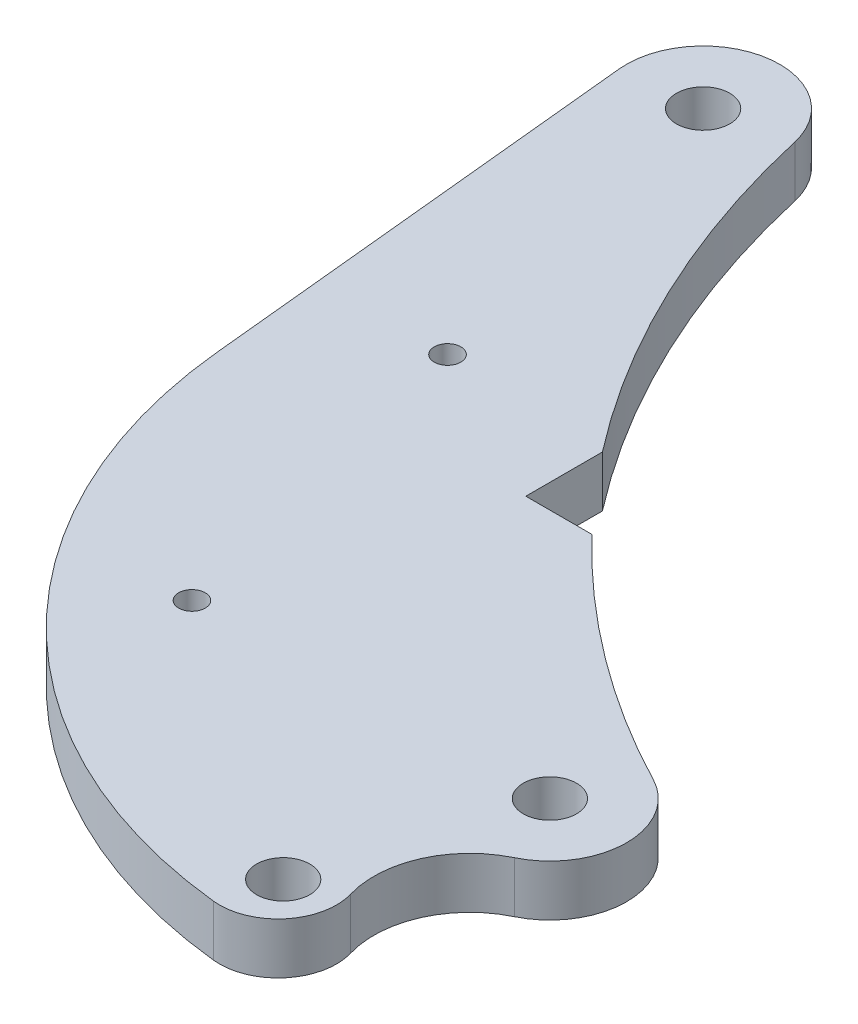
from build123d import *

# Parameters (mm, degrees)
SKETCH1_R           = 3.175
SKETCH1_R_2         = 1.5875
BOSS_EXTRUDE1_DEPTH = 3.048


with BuildPart() as part:
    # Sketch1 → Boss-Extrude1 (new, symmetric)
    with BuildSketch(Plane(origin=(0, 0, 0), x_dir=(1, 0, 0), z_dir=(0, 1, 0))):
        with BuildLine():
            Line((-9.099235244, -0.903689094), (-3.807571336, -54.185393016))
            ThreePointArc((-3.807571336, -54.185393016), (14.328591511, -92.658850534), (52.678421921, -111.054987185))
            ThreePointArc((52.678421921, -111.054987185), (58.779230265, -108.583775292), (60.117170229, -102.138880621))
            ThreePointArc((60.117170229, -102.138880621), (60.633172254, -94.28427436), (66.105273821, -88.625899853))
            ThreePointArc((66.105273821, -88.625899853), (71.266071099, -80.525710338), (66.339661954, -72.280870032))
            ThreePointArc((66.339661954, -72.280870032), (50.960508132, -62.625906994), (37.347898209, -50.607856626))
            Line((37.347898209, -50.607856626), (29.464, -50.607856626))
            Line((29.464, -50.607856626), (29.464, -41.476271417))
            ThreePointArc((29.464, -41.476271417), (16.820103433, -20.840439396), (8.915029824, 2.033464836))
            ThreePointArc((8.915029824, 2.033464836), (-1.47146227, 9.024828796), (-9.099235244, -0.903689094))
        make_face()
        Circle(SKETCH1_R, mode=Mode.SUBTRACT)
        with Locations((62.123011123, -80.394598631)):
            Circle(SKETCH1_R, mode=Mode.SUBTRACT)
        with Locations((54.567235003, -104.644758367)):
            Circle(SKETCH1_R, mode=Mode.SUBTRACT)
        with Locations((10.16, -40.64)):
            Circle(SKETCH1_R_2, mode=Mode.SUBTRACT)
        with Locations((20.32, -81.28)):
            Circle(SKETCH1_R_2, mode=Mode.SUBTRACT)
    extrude(amount=BOSS_EXTRUDE1_DEPTH, both=True)


solid = part.part
